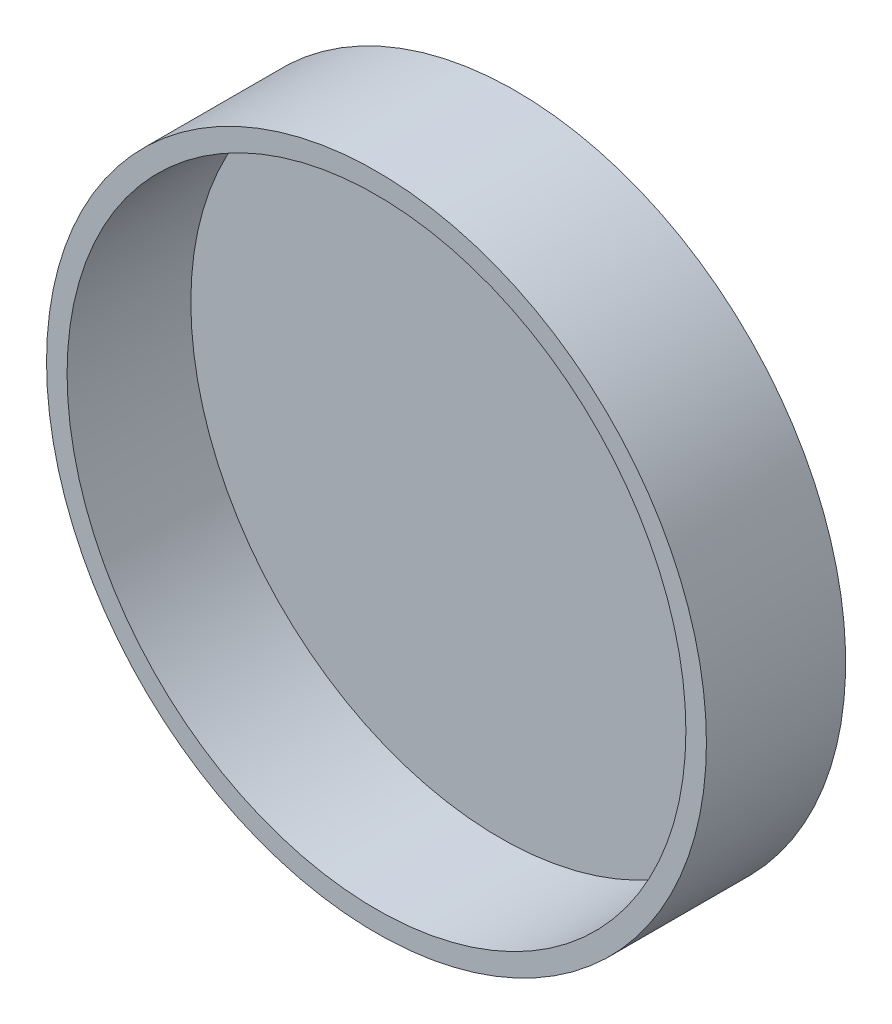
from build123d import *

# Parameters (mm, degrees)
SKETCH1_R           = 54.172889722
SKETCH1_R_2         = 50.8
BOSS_EXTRUDE1_DEPTH = 20.32
SKETCH2_R           = 54.172889722
BOSS_EXTRUDE2_DEPTH = 2.54


with BuildPart() as part:
    # Sketch1 → Boss-Extrude1 (new body)
    with BuildSketch(Plane.XY):
        with Locations((-33.833122115, 23.922409576)):
            Circle(SKETCH1_R)
        with Locations((-33.833122115, 23.922409576)):
            Circle(SKETCH1_R_2, mode=Mode.SUBTRACT)
    extrude(amount=BOSS_EXTRUDE1_DEPTH)

    # Sketch2 → Boss-Extrude2 (add)
    with BuildSketch(Plane(origin=(0, 0, 0), x_dir=(-1, 0, 0), z_dir=(0, 0, -1))):
        with Locations((33.833122115, 23.922409576)):
            Circle(SKETCH2_R)
    extrude(amount=BOSS_EXTRUDE2_DEPTH)


solid = part.part
